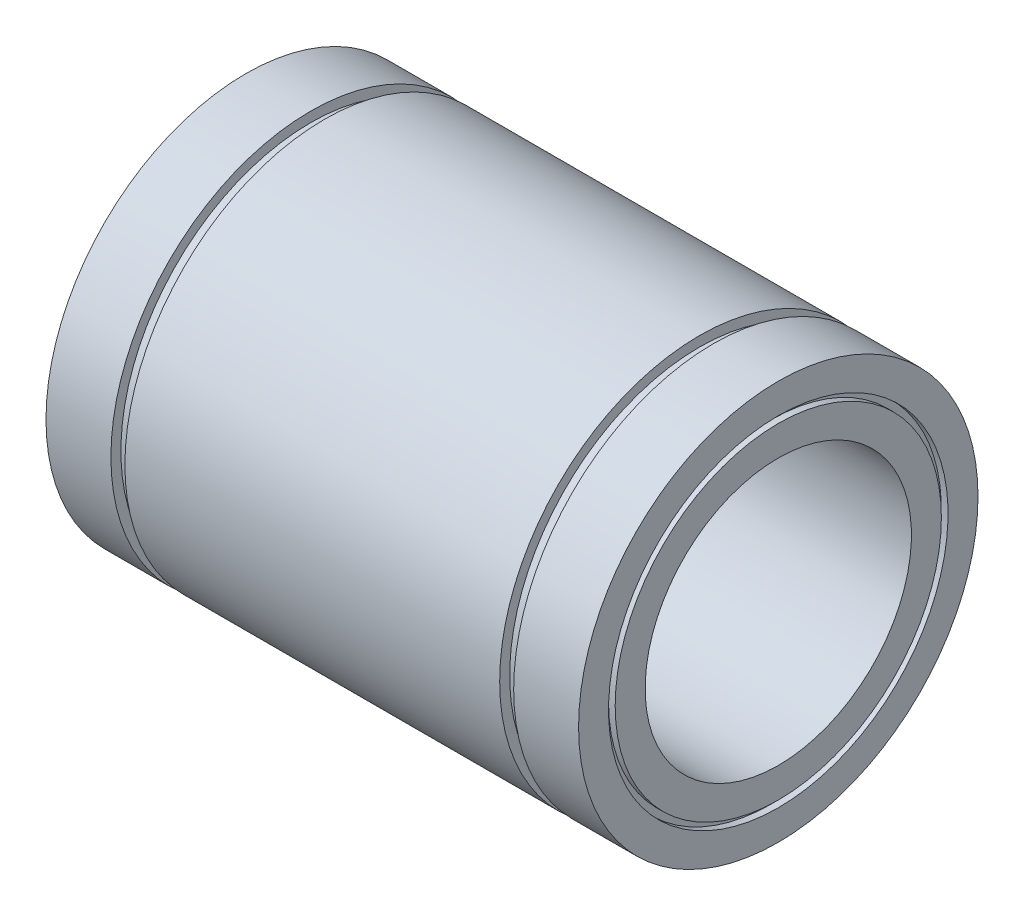
from build123d import *


with BuildPart() as part:
    # Esboço1 → Revolução1 (revolve)
    with BuildSketch(Plane.XY):
        Polygon((-40, 30), (-30.25, 30), (-30.25, 28.5), (-28.15, 28.5), (-28.15, 30), (28.15, 30), (28.15, 28.5), (30.25, 28.5), (30.25, 30), (40, 30), (40, 25.5), (39, 25.5), (39, 24.5), (40, 24.5), (40, 20), (-40, 20), (-40, 24.5), (-39, 24.5), (-39, 25.5), (-40, 25.5), align=None)
    revolve(axis=Axis((0, 0, 0), (-1, 0, 0)))


solid = part.part
